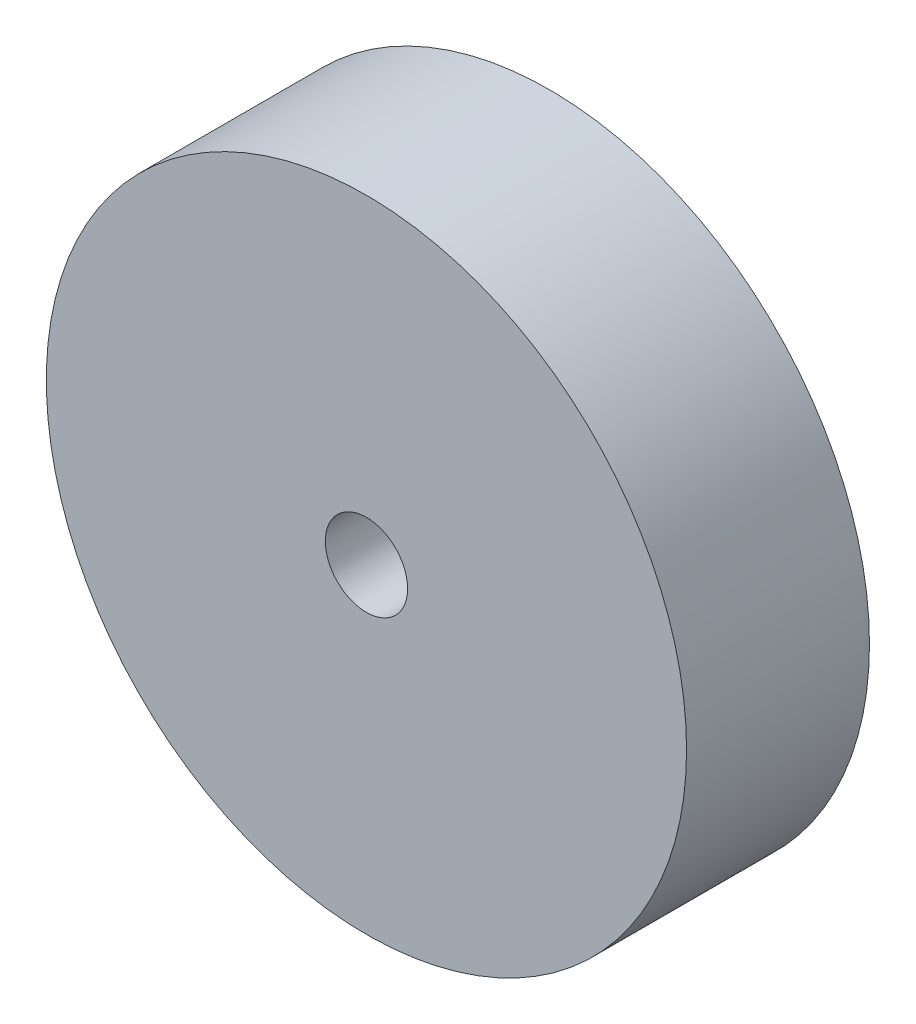
from build123d import *

# Parameters (mm, degrees)
SKETCH1_R           = 35
BOSS_EXTRUDE1_DEPTH = 20
SKETCH2_R           = 4.5
CUT_EXTRUDE1_DEPTH  = 20


with BuildPart() as part:
    # Sketch1 → Boss-Extrude1 (new body)
    with BuildSketch(Plane.XY):
        Circle(SKETCH1_R)
    extrude(amount=BOSS_EXTRUDE1_DEPTH)

    # Sketch2 → Cut-Extrude1 (cut)
    with BuildSketch(Plane.XY.offset(20)):
        Circle(SKETCH2_R)
    extrude(amount=-CUT_EXTRUDE1_DEPTH, mode=Mode.SUBTRACT)


solid = part.part
